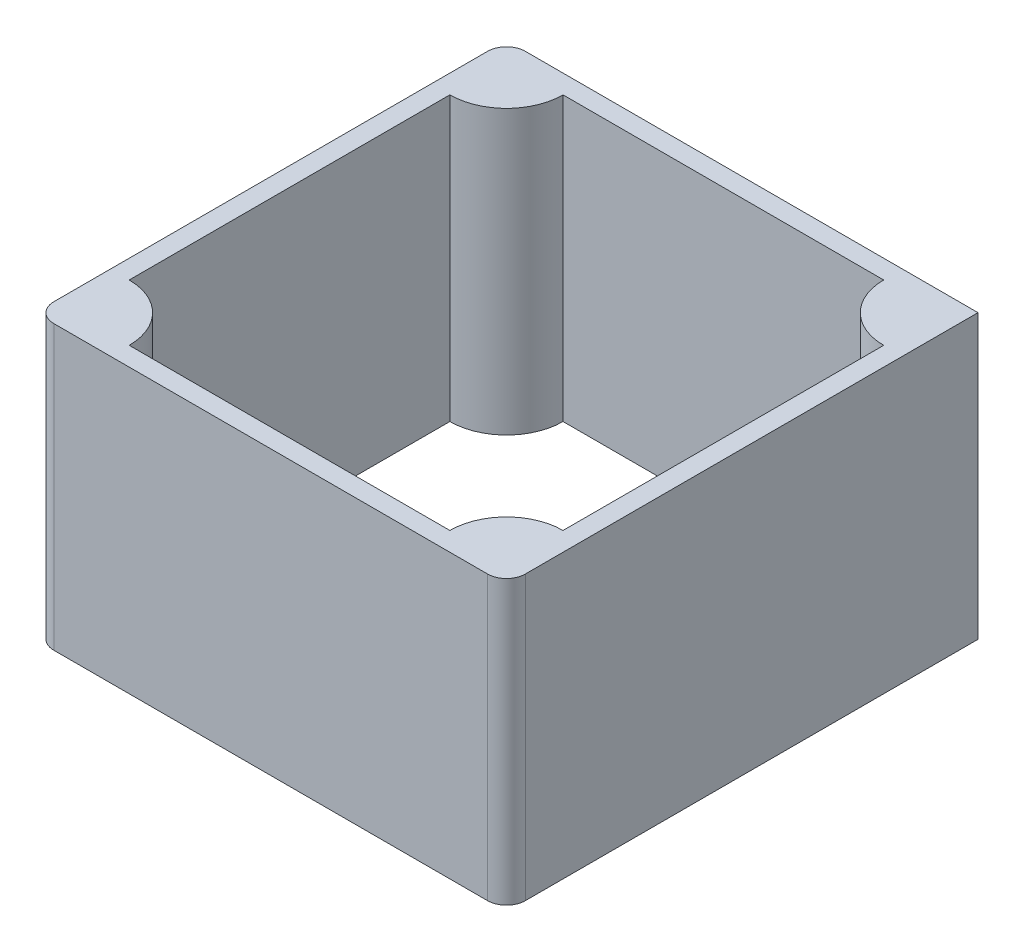
from build123d import *

# Parameters (mm, degrees)
ESQUISSE1_W        = 50
ESQUISSE1_H        = 50
BOSS_EXTRU_1_DEPTH = 30
CONG_1_R           = 2


with BuildPart() as part:
    # Esquisse1 → Boss.-Extru.1 (new body)
    with BuildSketch(Plane(origin=(0, 0, 0), x_dir=(1, 0, 0), z_dir=(0, 1, 0))):
        with Locations((13.704515327, -15.337721188)):
            Rectangle(ESQUISSE1_W, ESQUISSE1_H)
        with BuildLine():
            Line((-3.295484673, 7.662278812), (30.704515327, 7.662278812))
            ThreePointArc((30.704515327, 7.662278812), (32.461874639, 3.419638124), (36.704515327, 1.662278812))
            Line((36.704515327, 1.662278812), (36.704515327, -32.337721188))
            ThreePointArc((36.704515327, -32.337721188), (32.461874639, -34.095080501), (30.704515327, -38.337721188))
            Line((30.704515327, -38.337721188), (-3.295484673, -38.337721188))
            ThreePointArc((-3.295484673, -38.337721188), (-5.052843986, -34.095080501), (-9.295484673, -32.337721188))
            Line((-9.295484673, -32.337721188), (-9.295484673, 1.662278812))
            ThreePointArc((-9.295484673, 1.662278812), (-5.052843986, 3.419638124), (-3.295484673, 7.662278812))
        make_face(mode=Mode.SUBTRACT)
    extrude(amount=BOSS_EXTRU_1_DEPTH)

    # Congé1
    cong_1_edges = [part.edges().sort_by_distance(p)[0] for p in [
        (-11.295484673, 15, -9.662278812),
        (38.704515327, 15, 40.337721188),
        (-11.295484673, 15, 40.337721188),
    ]]
    fillet(cong_1_edges, radius=CONG_1_R)


solid = part.part
